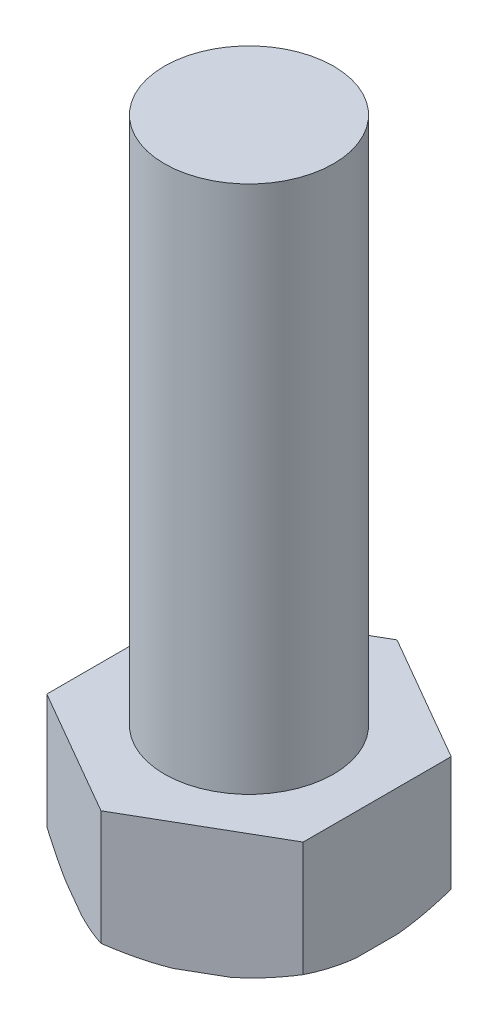
from build123d import *

# Parameters (mm, degrees)
BOSS_EXTRUDE1_DEPTH = 6
SKETCH6_R           = 4
BOSS_EXTRUDE2_DEPTH = 25


with BuildPart() as part:
    # Sketch1 → Boss-Extrude1 (new body)
    with BuildSketch(Plane(origin=(0, 0, 0), x_dir=(1, 0, 0), z_dir=(0, 1, 0))):
        Polygon((6.062177826, 3.5), (0, 7), (-6.062177826, 3.5), (-6.062177826, -3.5), (0, -7), (6.062177826, -3.5), align=None)
    extrude(amount=BOSS_EXTRUDE1_DEPTH)

    # Sketch5 → Cut-Revolve5 (revolve, cut)
    with BuildSketch(Plane(origin=(0, 0, 0), x_dir=(0, 0, -1), z_dir=(1, 0, 0))):
        Polygon((5.527622028, -0.407756563), (7.359129526, 0.805892984), (7.359129526, -0.407756563), align=None)
    revolve(axis=Axis((0, 0, 0), (0, 1, 0)), mode=Mode.SUBTRACT)

    # Sketch6 → Boss-Extrude2 (add)
    with BuildSketch(Plane(origin=(0, 6, 0), x_dir=(1, 0, 0), z_dir=(0, 1, 0))):
        with Locations(Location((0, 0, 0), (0, 0, 270))):  # turned: the seam where the file's is
            Circle(SKETCH6_R)
    extrude(amount=BOSS_EXTRUDE2_DEPTH)


solid = part.part
